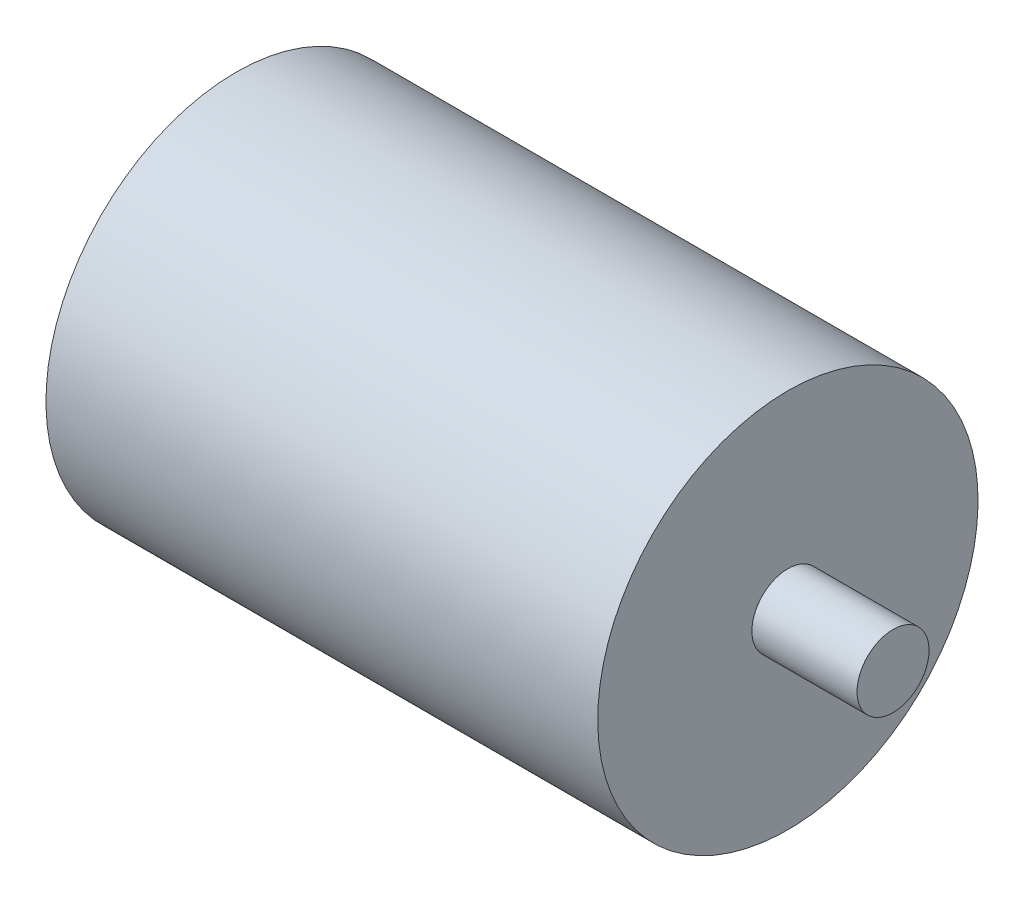
from build123d import *

# Parameters (mm, degrees)
SWEEP1_PROFILE_R = 33.528
SWEEP2_PROFILE_R = 6.35
SWEEP3_PROFILE_R = 6.35


with BuildPart() as part:
    # Sweep1: sweep along a path in Sketch1
    with BuildLine(Plane.XY) as sweep1_path:
        Line((-48.641, 0), (48.641, 0))
    # Sweep1 profile (on start of the path) → Sweep1 (sweep)
    with BuildSketch(Plane.YZ.offset(-48.641)):
        Circle(SWEEP1_PROFILE_R)
    sweep(path=sweep1_path.line)

    # Sweep2: sweep along a path in Sketch11
    with BuildLine(Plane.XY) as sweep2_path:
        Line((48.641, 0), (67.183, 0))
    # Sweep2 profile (on start of the path) → Sweep2 (sweep)
    with BuildSketch(Plane.YZ.offset(48.641)):
        Circle(SWEEP2_PROFILE_R)
    sweep(path=sweep2_path.line)

    # Sweep3: sweep along a path in Sketch30
    with BuildLine(Plane.XY) as sweep3_path:
        Line((-48.641, 0), (-67.183, 0))
    # Sweep3 profile (on start of the path) → Sweep3 (sweep)
    with BuildSketch(Plane(origin=(-48.641, 0, 0), x_dir=(0, -1, 0), z_dir=(-1, 0, 0))):
        Circle(SWEEP3_PROFILE_R)
    sweep(path=sweep3_path.line)


solid = part.part
